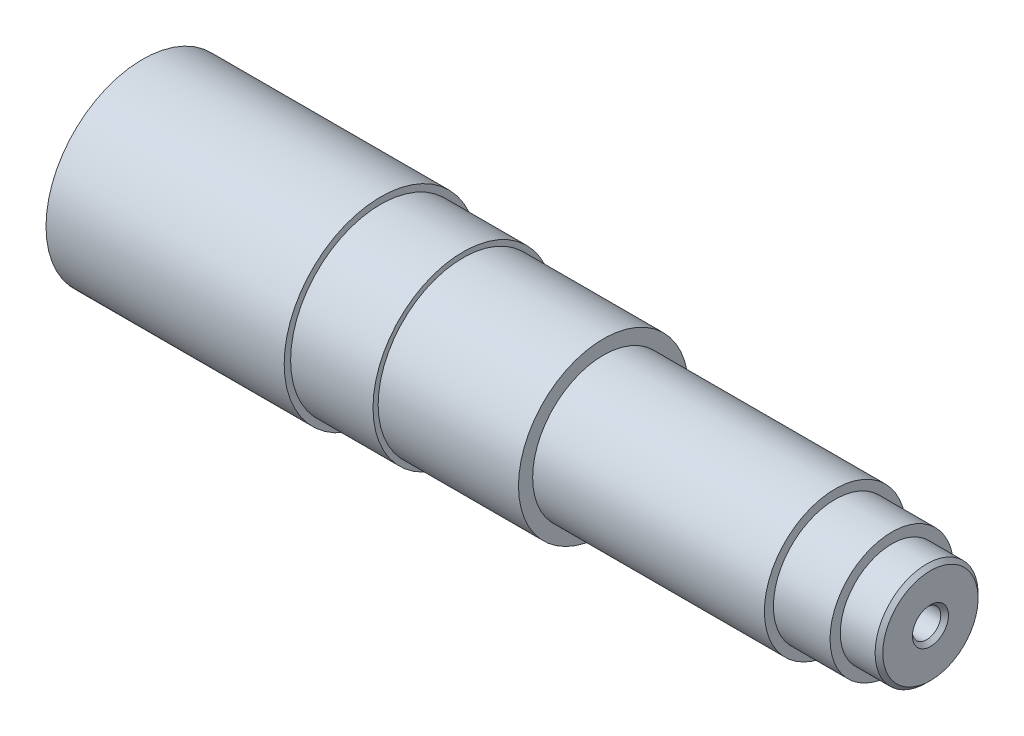
from build123d import *

# Parameters (mm, degrees)
CSK_FOR_M10_COUNTERSUNK_FLAT_HEAD_SCREW1_D           = 11
CSK_FOR_M10_COUNTERSUNK_FLAT_HEAD_SCREW1_DEPTH       = 10.695266595
CSK_FOR_M10_COUNTERSUNK_FLAT_HEAD_SCREW1_CSINK_D     = 14
CSK_FOR_M10_COUNTERSUNK_FLAT_HEAD_SCREW1_CSINK_ANGLE = 90
CSK_FOR_M10_COUNTERSUNK_FLAT_HEAD_SCREW1_TIP         = 3.304733405
CSK_FOR_M10_COUNTERSUNK_FLAT_HEAD_SCREW2_D           = 11
CSK_FOR_M10_COUNTERSUNK_FLAT_HEAD_SCREW2_DEPTH       = 10.695266595
CSK_FOR_M10_COUNTERSUNK_FLAT_HEAD_SCREW2_CSINK_D     = 14
CSK_FOR_M10_COUNTERSUNK_FLAT_HEAD_SCREW2_CSINK_ANGLE = 90
CSK_FOR_M10_COUNTERSUNK_FLAT_HEAD_SCREW2_TIP         = 3.304733405


with BuildPart() as part:
    # Sketch1 → Revolve1 (revolve)
    with BuildSketch(Plane.XY):
        Polygon((0, 0), (0, 12.2), (2.5, 14.7), (17, 14.7), (17, 37.5), (109.5, 37.5), (109.5, 35), (141.5, 35), (141.5, 33), (196, 33), (196, 27.5), (286, 27.5), (286, 24), (308, 24), (308, 20), (321.5, 20), (323, 18.5), (323, 0), align=None)
    revolve(axis=Axis((0, 0, 0), (1, 0, 0)))

    # CSK for M10 Countersunk Flat Head Screw1
    with Locations(Plane.ZY):
        with Locations((0, 0)):
            CounterSinkHole(CSK_FOR_M10_COUNTERSUNK_FLAT_HEAD_SCREW1_D / 2, CSK_FOR_M10_COUNTERSUNK_FLAT_HEAD_SCREW1_CSINK_D / 2, depth=CSK_FOR_M10_COUNTERSUNK_FLAT_HEAD_SCREW1_DEPTH, counter_sink_angle=CSK_FOR_M10_COUNTERSUNK_FLAT_HEAD_SCREW1_CSINK_ANGLE)
            with Locations((0, 0, -(CSK_FOR_M10_COUNTERSUNK_FLAT_HEAD_SCREW1_DEPTH + CSK_FOR_M10_COUNTERSUNK_FLAT_HEAD_SCREW1_TIP / 2))):  # 118° drill point
                Cone(0, CSK_FOR_M10_COUNTERSUNK_FLAT_HEAD_SCREW1_D / 2, CSK_FOR_M10_COUNTERSUNK_FLAT_HEAD_SCREW1_TIP, mode=Mode.SUBTRACT)

    # CSK for M10 Countersunk Flat Head Screw2
    with Locations(Plane(origin=(323, 0, 0), x_dir=(0, 0, -1), z_dir=(1, 0, 0))):
        with Locations((0, 0)):
            CounterSinkHole(CSK_FOR_M10_COUNTERSUNK_FLAT_HEAD_SCREW2_D / 2, CSK_FOR_M10_COUNTERSUNK_FLAT_HEAD_SCREW2_CSINK_D / 2, depth=CSK_FOR_M10_COUNTERSUNK_FLAT_HEAD_SCREW2_DEPTH, counter_sink_angle=CSK_FOR_M10_COUNTERSUNK_FLAT_HEAD_SCREW2_CSINK_ANGLE)
            with Locations((0, 0, -(CSK_FOR_M10_COUNTERSUNK_FLAT_HEAD_SCREW2_DEPTH + CSK_FOR_M10_COUNTERSUNK_FLAT_HEAD_SCREW2_TIP / 2))):  # 118° drill point
                Cone(0, CSK_FOR_M10_COUNTERSUNK_FLAT_HEAD_SCREW2_D / 2, CSK_FOR_M10_COUNTERSUNK_FLAT_HEAD_SCREW2_TIP, mode=Mode.SUBTRACT)


solid = part.part
